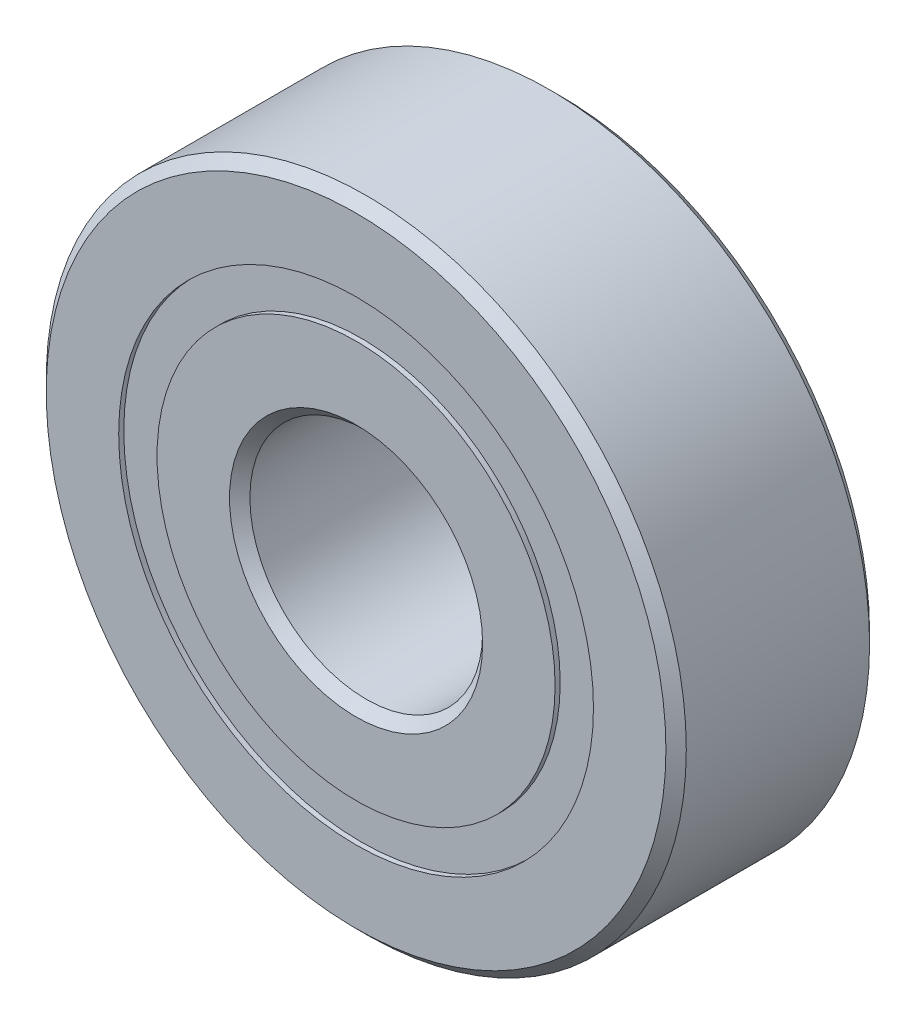
from build123d import *

# Parameters (mm, degrees)
CIRPATTERN1_COUNT = 12
SKETCH5_W         = 1.635478413
SKETCH5_H         = 1.318681318


with BuildPart() as part:
    # Sketch6 → Revolve1 (revolve)
    with BuildSketch(Plane(origin=(0, 0, 0), x_dir=(0, 0, -1), z_dir=(1, 0, 0))):
        with BuildLine():
            Line((-3.5, 10.65), (-3.5, 8.159340659))
            Line((-3.5, 8.159340659), (-1.555555556, 8.159340659))
            ThreePointArc((-1.555555556, 8.159340659), (0, 9.189521587), (1.555555556, 8.159340659))
            Line((1.555555556, 8.159340659), (3.5, 8.159340659))
            Line((3.5, 8.159340659), (3.5, 10.65))
            Line((3.5, 10.65), (3.15, 11))
            Line((3.15, 11), (-3.15, 11))
            Line((-3.15, 11), (-3.5, 10.65))
        make_face()
        with BuildLine():
            Line((-3.5, 4.35), (-3.5, 6.840659341))
            Line((-3.5, 6.840659341), (-1.555555556, 6.840659341))
            ThreePointArc((-1.555555556, 6.840659341), (0, 5.810478413), (1.555555556, 6.840659341))
            Line((1.555555556, 6.840659341), (3.5, 6.840659341))
            Line((3.5, 6.840659341), (3.5, 4.35))
            Line((3.5, 4.35), (3.15, 4))
            Line((3.15, 4), (-3.15, 4))
            Line((-3.15, 4), (-3.5, 4.35))
        make_face()
    revolve(axis=Axis((0, 0, 3.5), (0, 0, -1)))



with BuildPart() as body_2:
    # Sketch4 → Revolve2 (revolve)
    with BuildSketch(Plane(origin=(0, 0, 0), x_dir=(0, 0, -1), z_dir=(1, 0, 0))):
        with BuildLine():
            Line((-1.689521587, 7.5), (1.689521587, 7.5))
            ThreePointArc((1.689521587, 7.5), (0, 9.189521587), (-1.689521587, 7.5))
        make_face()
    revolve(axis=Axis((0, 7.5, 1.689521587), (0, 0, -1)))


with BuildPart() as cirpattern1_1:
    # CirPattern1: pattern copy
    add(body_2.part.rotate(Axis((0, 0, 0), (0, 0, 1)), 1 * 360 / CIRPATTERN1_COUNT))


with BuildPart() as cirpattern1_2:
    # CirPattern1: pattern copy
    add(body_2.part.rotate(Axis((0, 0, 0), (0, 0, 1)), 2 * 360 / CIRPATTERN1_COUNT))


with BuildPart() as cirpattern1_3:
    # CirPattern1: pattern copy
    add(body_2.part.rotate(Axis((0, 0, 0), (0, 0, 1)), 3 * 360 / CIRPATTERN1_COUNT))


with BuildPart() as cirpattern1_4:
    # CirPattern1: pattern copy
    add(body_2.part.rotate(Axis((0, 0, 0), (0, 0, 1)), 4 * 360 / CIRPATTERN1_COUNT))


with BuildPart() as cirpattern1_5:
    # CirPattern1: pattern copy
    add(body_2.part.rotate(Axis((0, 0, 0), (0, 0, 1)), 5 * 360 / CIRPATTERN1_COUNT))


with BuildPart() as cirpattern1_6:
    # CirPattern1: pattern copy
    add(body_2.part.rotate(Axis((0, 0, 0), (0, 0, 1)), 6 * 360 / CIRPATTERN1_COUNT))


with BuildPart() as cirpattern1_7:
    # CirPattern1: pattern copy
    add(body_2.part.rotate(Axis((0, 0, 0), (0, 0, 1)), 7 * 360 / CIRPATTERN1_COUNT))


with BuildPart() as cirpattern1_8:
    # CirPattern1: pattern copy
    add(body_2.part.rotate(Axis((0, 0, 0), (0, 0, 1)), 8 * 360 / CIRPATTERN1_COUNT))


with BuildPart() as cirpattern1_9:
    # CirPattern1: pattern copy
    add(body_2.part.rotate(Axis((0, 0, 0), (0, 0, 1)), 9 * 360 / CIRPATTERN1_COUNT))


with BuildPart() as cirpattern1_10:
    # CirPattern1: pattern copy
    add(body_2.part.rotate(Axis((0, 0, 0), (0, 0, 1)), 10 * 360 / CIRPATTERN1_COUNT))


with BuildPart() as cirpattern1_11:
    # CirPattern1: pattern copy
    add(body_2.part.rotate(Axis((0, 0, 0), (0, 0, 1)), 11 * 360 / CIRPATTERN1_COUNT))


with BuildPart() as part_1:
    add(part.part)

    add(body_2.part)  # Revolve3 merges body 2

    add(cirpattern1_1.part)  # Revolve3 merges CirPattern1_1

    add(cirpattern1_2.part)  # Revolve3 merges CirPattern1_2

    add(cirpattern1_3.part)  # Revolve3 merges CirPattern1_3

    add(cirpattern1_4.part)  # Revolve3 merges CirPattern1_4

    add(cirpattern1_5.part)  # Revolve3 merges CirPattern1_5

    add(cirpattern1_6.part)  # Revolve3 merges CirPattern1_6

    add(cirpattern1_7.part)  # Revolve3 merges CirPattern1_7

    add(cirpattern1_8.part)  # Revolve3 merges CirPattern1_8

    add(cirpattern1_9.part)  # Revolve3 merges CirPattern1_9

    add(cirpattern1_10.part)  # Revolve3 merges CirPattern1_10

    add(cirpattern1_11.part)  # Revolve3 merges CirPattern1_11
    # Sketch5 → Revolve3 (revolve)
    with BuildSketch(Plane(origin=(0, 0, 0), x_dir=(0, 0, -1), z_dir=(1, 0, 0))):
        with Locations((-2.507260794, 7.5)):
            Rectangle(SKETCH5_W, SKETCH5_H)
        with Locations((2.507260794, 7.5)):
            Rectangle(SKETCH5_W, SKETCH5_H)
    revolve(axis=Axis((0, 0, 3.5), (0, 0, -1)))


solid = part_1.part
